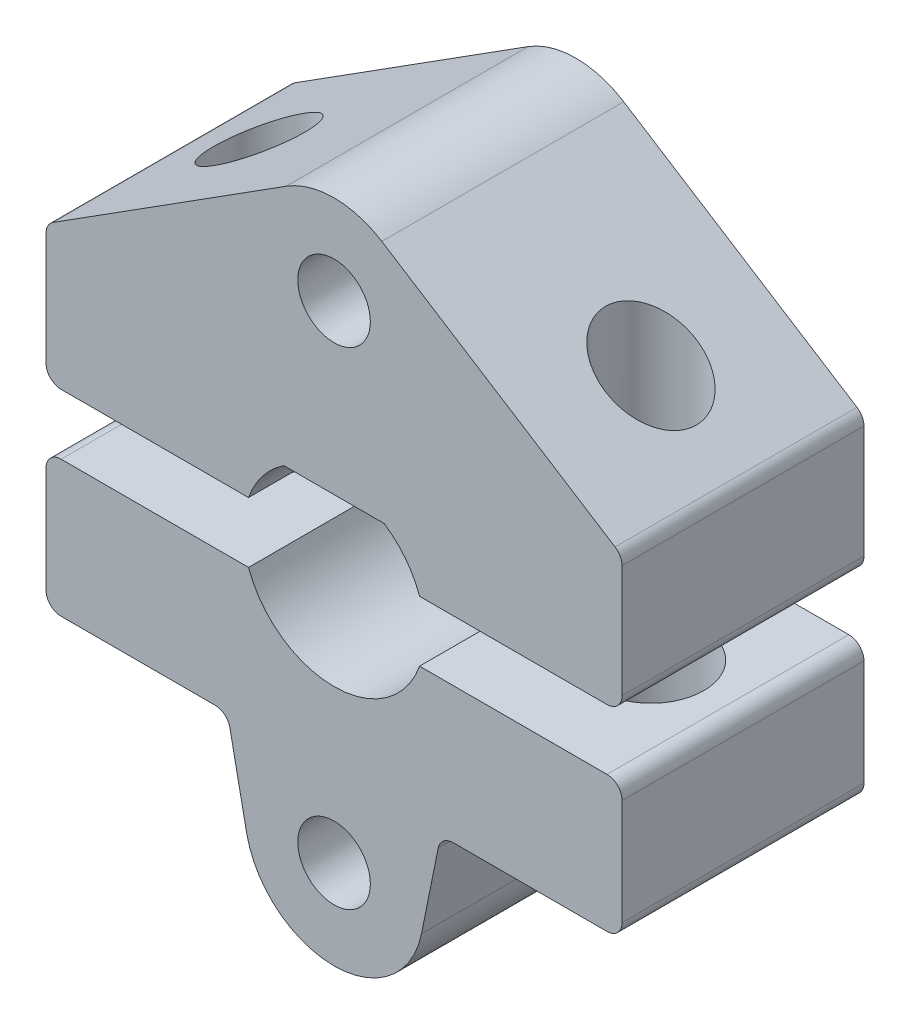
from build123d import *

# Parameters (mm, degrees)
SKETCH_1_R          = 1.2
EXTRUDE_1_DEPTH     = 8
EXTRUDE_1_2_DEPTH   = 8
SKETCH_2_R          = 1.5
CUT_EXTRUDE_1_DEPTH = 17.5
SKETCH_3_R          = 1.75
CUT_EXTRUDE_2_DEPTH = 4.5


with BuildPart() as part:
    # 草图1 → 凸台-拉伸1 (new body)
    with BuildSketch(Plane.XY):
        with BuildLine():
            Line((-1.658312395, 2.5), (1.658312395, 2.5))
            ThreePointArc((1.658312395, 2.5), (2.365419176, 1.84520788), (2.828427125, 1))
            Line((2.828427125, 1), (9.026279442, 1))
            ThreePointArc((9.026279442, 1), (9.379832832, 1.146446609), (9.526279442, 1.5))
            Line((9.526279442, 1.5), (9.526279442, 5.22507425))
            ThreePointArc((9.526279442, 5.22507425), (9.464414867, 5.465983671), (9.294130046, 5.647278056))
            Line((9.294130046, 5.647278056), (1.580318565, 10.541002455))
            ThreePointArc((1.580318565, 10.541002455), (0, 11), (-1.580318565, 10.541002455))
            Line((-1.580318565, 10.541002455), (-9.294130046, 5.647278056))
            ThreePointArc((-9.294130046, 5.647278056), (-9.464414867, 5.465983671), (-9.526279442, 5.22507425))
            Line((-9.526279442, 5.22507425), (-9.526279442, 1.5))
            ThreePointArc((-9.526279442, 1.5), (-9.379832832, 1.146446609), (-9.026279442, 1))
            Line((-9.026279442, 1), (-2.828427125, 1))
            ThreePointArc((-2.828427125, 1), (-2.365419176, 1.84520788), (-1.658312395, 2.5))
        make_face()
        with Locations((0, 8.05)):
            Circle(SKETCH_1_R, mode=Mode.SUBTRACT)
    extrude(amount=EXTRUDE_1_DEPTH)


with BuildPart() as body_2:
    # 草图1 → Extrude 1 2 (new body)
    with BuildSketch(Plane.XY):
        with BuildLine():
            Line((-9.026279442, -1), (-2.828427125, -1))
            ThreePointArc((-2.828427125, -1), (0, -3), (2.828427125, -1))
            Line((2.828427125, -1), (9.026279442, -1))
            ThreePointArc((9.026279442, -1), (9.379832832, -1.146446609), (9.526279442, -1.5))
            Line((9.526279442, -1.5), (9.526279442, -5))
            ThreePointArc((9.526279442, -5), (9.379832832, -5.353553391), (9.026279442, -5.5))
            Line((9.026279442, -5.5), (3.935174447, -5.5))
            ThreePointArc((3.935174447, -5.5), (3.6186464, -5.612947037), (3.445121974, -5.900760016))
            Line((3.445121974, -5.900760016), (2.891309587, -8.635515904))
            ThreePointArc((2.891309587, -8.635515904), (0, -11), (-2.891309587, -8.635515904))
            Line((-2.891309587, -8.635515904), (-3.445121974, -5.900760016))
            ThreePointArc((-3.445121974, -5.900760016), (-3.6186464, -5.612947037), (-3.935174447, -5.5))
            Line((-3.935174447, -5.5), (-9.026279442, -5.5))
            ThreePointArc((-9.026279442, -5.5), (-9.379832832, -5.353553391), (-9.526279442, -5))
            Line((-9.526279442, -5), (-9.526279442, -1.5))
            ThreePointArc((-9.526279442, -1.5), (-9.379832832, -1.146446609), (-9.026279442, -1))
        make_face()
        with Locations((0, -8.05)):
            Circle(SKETCH_1_R, mode=Mode.SUBTRACT)
    extrude(amount=EXTRUDE_1_2_DEPTH)


with BuildPart() as cut_extrude_1_tool:
    # 草图2 → 切除-拉伸1 (new body, through all)
    with BuildSketch(Plane.XZ.offset(5.5)):
        with Locations((6.480726944, 4)):
            Circle(SKETCH_2_R)
        with Locations((-6.480726944, 4)):
            Circle(SKETCH_2_R)
    extrude(amount=-CUT_EXTRUDE_1_DEPTH)


with BuildPart() as part_1:
    add(part.part)

    # 切除-拉伸1: cut by cut_extrude_1_tool
    add(cut_extrude_1_tool.part, mode=Mode.SUBTRACT)


with BuildPart() as body_2_1:
    add(body_2.part)

    # 切除-拉伸1: cut by cut_extrude_1_tool
    add(cut_extrude_1_tool.part, mode=Mode.SUBTRACT)

    # 草图3 → 切除-拉伸2 (cut)
    with BuildSketch(Plane.XZ.offset(5.5)):
        with Locations((-6.480726944, 4)):
            Circle(SKETCH_3_R)
        with Locations((6.480726944, 4)):
            Circle(SKETCH_3_R)
    extrude(amount=-CUT_EXTRUDE_2_DEPTH, mode=Mode.SUBTRACT)


solid = Compound([part_1.part, body_2_1.part])
